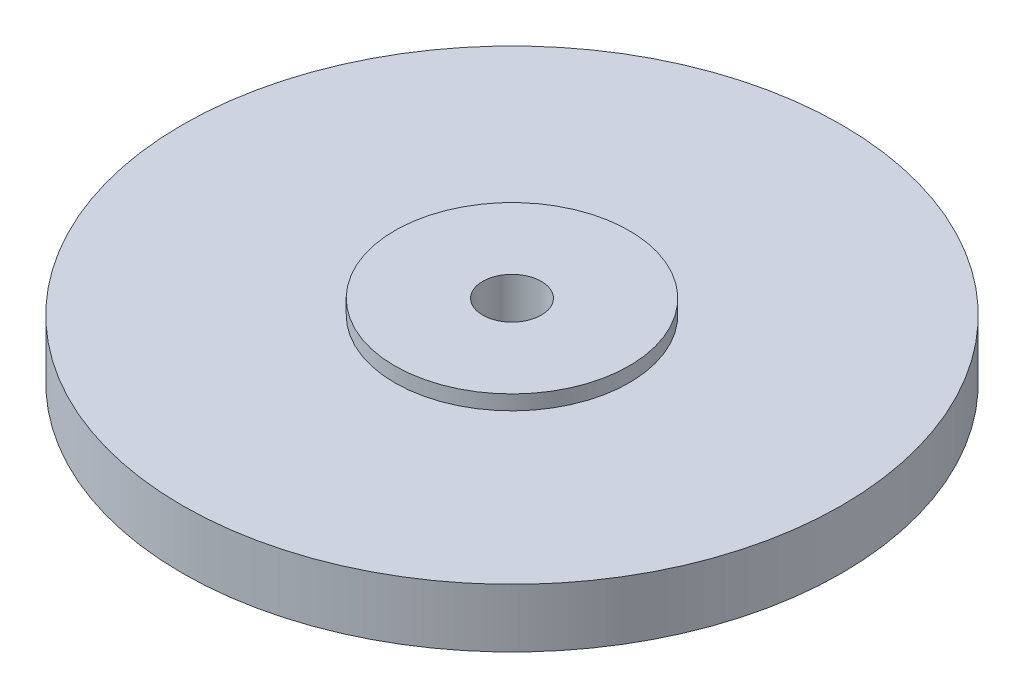
from build123d import *


with BuildPart() as part:
    # Esquisse1 → Révolution1 (revolve)
    with BuildSketch(Plane.XY):
        Polygon((2, 3), (2, -13), (4, -13), (4, -2), (22.5, -2), (22.5, 2), (8, 2), (8, 3), align=None)
    revolve(axis=Axis((0, 8.626576325, 0), (0, -1, 0)))


solid = part.part
